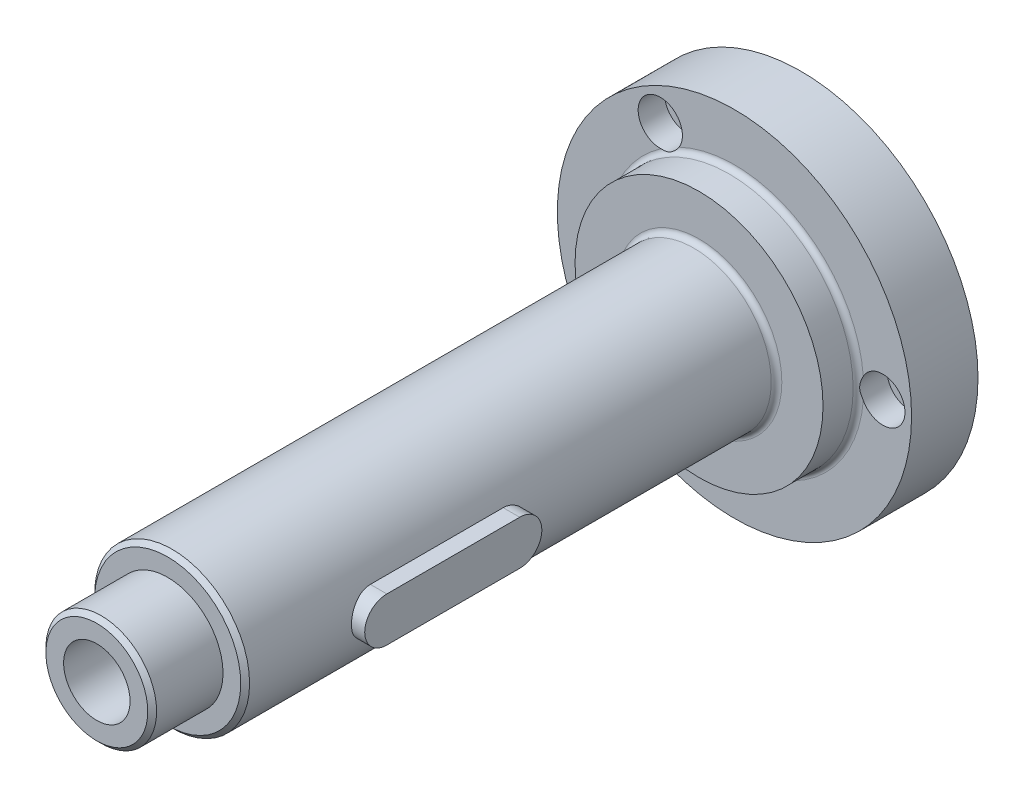
from build123d import *

# Parameters (mm, degrees)
CROQUIS1_R              = 28
SALIENTE_EXTRUIR1_DEPTH = 3
CROQUIS2_R              = 40
SALIENTE_EXTRUIR2_DEPTH = 15
CROQUIS3_R              = 28
SALIENTE_EXTRUIR3_DEPTH = 8
CROQUIS4_R              = 17.5
SALIENTE_EXTRUIR4_DEPTH = 120
CROQUIS5_R              = 12.5
SALIENTE_EXTRUIR5_DEPTH = 16
REDONDEO1_R             = 1.2
CHAFL_N1_SIZE           = 1
CORTAR_EXTRUIR1_START   = 12.5
CORTAR_EXTRUIR1_DEPTH   = 33.2
CROQUIS8_R              = 3.25
CORTAR_EXTRUIR2_DEPTH   = 33.2
MATRIZC1_COUNT          = 3
CROQUIS9_R              = 5
CORTAR_EXTRUIR3_DEPTH   = 6
MATRIZC2_COUNT          = 3
CROQUIS10_R             = 5
CORTAR_EXTRUIR4_DEPTH   = 23.5
MATRIZC3_COUNT          = 3
SALIENTE_EXTRUIR6_DEPTH = 8


with BuildPart() as part:
    # Croquis1 → Saliente-Extruir1 (new body)
    with BuildSketch(Plane.XY):
        Circle(CROQUIS1_R)
    extrude(amount=SALIENTE_EXTRUIR1_DEPTH)

    # Croquis2 → Saliente-Extruir2 (add)
    with BuildSketch(Plane.XY.offset(3)):
        Circle(CROQUIS2_R)
    extrude(amount=SALIENTE_EXTRUIR2_DEPTH)

    # Croquis3 → Saliente-Extruir3 (add)
    with BuildSketch(Plane.XY.offset(18)):
        Circle(CROQUIS3_R)
    extrude(amount=SALIENTE_EXTRUIR3_DEPTH)

    # Croquis4 → Saliente-Extruir4 (add)
    with BuildSketch(Plane.XY.offset(26)):
        Circle(CROQUIS4_R)
    extrude(amount=SALIENTE_EXTRUIR4_DEPTH)

    # Croquis5 → Saliente-Extruir5 (add)
    with BuildSketch(Plane.XY.offset(146)):
        Circle(CROQUIS5_R)
    extrude(amount=SALIENTE_EXTRUIR5_DEPTH)

    # Redondeo1
    redondeo1_edges = [part.edges().sort_by_distance(p)[0] for p in [
        (-28, 0, 18),
        (-17.5, 0, 26),
    ]]
    fillet(redondeo1_edges, radius=REDONDEO1_R)

    # Chaflán1
    chafl_n1_edges = [part.edges().sort_by_distance(p)[0] for p in [
        (-17.5, 0, 146),
        (-12.5, 0, 162),
    ]]
    chamfer(chafl_n1_edges, length=CHAFL_N1_SIZE)

    # Croquis6 → Cortar-Extruir1 (cut)
    with BuildSketch(Plane(origin=(0, 0, 0), x_dir=(0, 0, -1), z_dir=(1, 0, 0)).offset(CORTAR_EXTRUIR1_START)):
        with BuildLine():
            Line((-117, 5), (-87, 5))
            ThreePointArc((-87, 5), (-82, 0), (-87, -5))
            Line((-87, -5), (-117, -5))
            ThreePointArc((-117, -5), (-122, 0), (-117, 5))
        make_face()
    extrude(amount=CORTAR_EXTRUIR1_DEPTH, mode=Mode.SUBTRACT)

    # Croquis7 → Cortar-Revolución1 (revolve, cut)
    with BuildSketch(Plane(origin=(0, 0, 0), x_dir=(0, 0, -1), z_dir=(1, 0, 0))):
        Polygon((-162, 0), (-162, 7.5), (-52, 7.5), (0, 8.89), (0, 0), align=None)
    revolve(axis=Axis((0, 0, 161), (0, 0, -1)), mode=Mode.SUBTRACT)

    # Croquis8 → Cortar-Extruir2 (cut)
    with BuildSketch(Plane(origin=(0, 0, 3), x_dir=(-1, 0, 0), z_dir=(0, 0, -1))):
        with Locations((-33.5, 0)):
            Circle(CROQUIS8_R)
    cortar_extruir2 = extrude(amount=-CORTAR_EXTRUIR2_DEPTH, mode=Mode.SUBTRACT)

    # MatrizC1: Cortar-Extruir2 ×3 about axis
    matrizc1_axis = Axis((0, 0, 0), (0, 0, 1))
    for i in range(1, MATRIZC1_COUNT):
        add(cortar_extruir2.rotate(matrizc1_axis, i * 360 / MATRIZC1_COUNT), mode=Mode.SUBTRACT)

    # Croquis9 → Cortar-Extruir3 (cut)
    with BuildSketch(Plane.XY.offset(18)):
        with Locations((33.5, 0)):
            Circle(CROQUIS9_R)
    cortar_extruir3 = extrude(amount=-CORTAR_EXTRUIR3_DEPTH, mode=Mode.SUBTRACT)

    # MatrizC2: Cortar-Extruir3 ×3 about axis
    matrizc2_axis = Axis((0, 0, 0), (0, 0, 1))
    for i in range(1, MATRIZC2_COUNT):
        add(cortar_extruir3.rotate(matrizc2_axis, i * 360 / MATRIZC2_COUNT), mode=Mode.SUBTRACT)

    # Croquis10 → Cortar-Extruir4 (cut)
    with BuildSketch(Plane.XY.offset(12)):
        with Locations((33.5, 0)):
            Circle(CROQUIS10_R)
    cortar_extruir4 = extrude(amount=CORTAR_EXTRUIR4_DEPTH, mode=Mode.SUBTRACT)

    # MatrizC3: Cortar-Extruir4 ×3 about axis
    matrizc3_axis = Axis((0, 0, 146), (0, 0, -1))
    for i in range(1, MATRIZC3_COUNT):
        add(cortar_extruir4.rotate(matrizc3_axis, i * 360 / MATRIZC3_COUNT), mode=Mode.SUBTRACT)


with BuildPart() as body_2:
    # Croquis11 → Saliente-Extruir6 (new body)
    with BuildSketch(Plane(origin=(12.5, 0, 0), x_dir=(0, 0, -1), z_dir=(1, 0, 0))):
        with BuildLine():
            Line((-117, -5), (-87, -5))
            ThreePointArc((-87, -5), (-82, 0), (-87, 5))
            Line((-87, 5), (-117, 5))
            ThreePointArc((-117, 5), (-122, 0), (-117, -5))
        make_face()
    extrude(amount=SALIENTE_EXTRUIR6_DEPTH)


solid = Compound([part.part, body_2.part])
